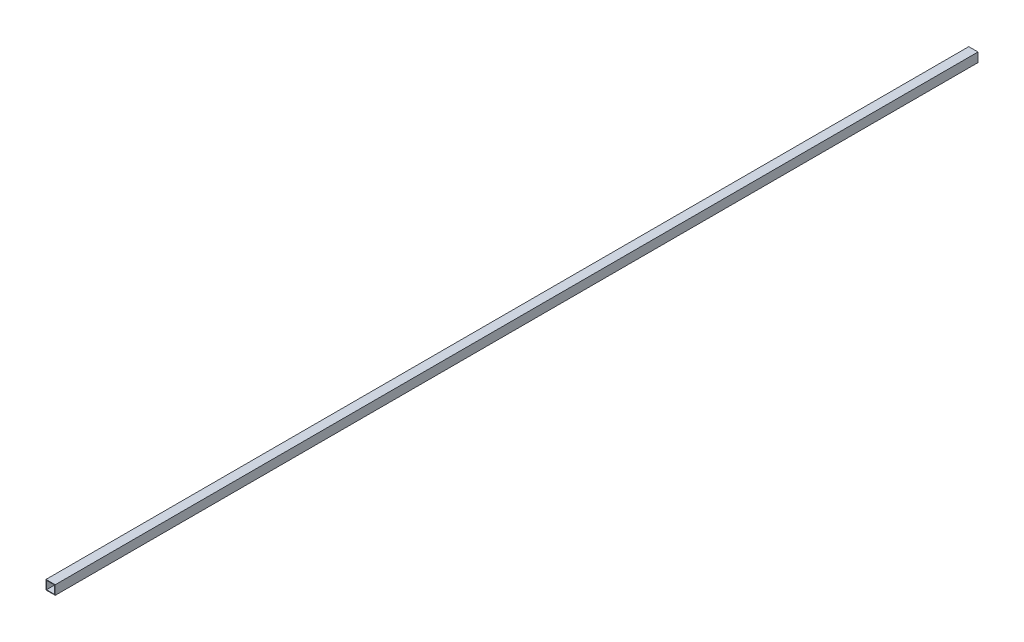
from build123d import *

# Parameters (mm, degrees)
SKETCH1_W           = 25.4
SKETCH1_H           = 25.4
SKETCH1_W_2         = 22.225
SKETCH1_H_2         = 22.225
BOSS_EXTRUDE1_DEPTH = 1270


with BuildPart() as part:
    # Sketch1 → Boss-Extrude1 (new body, symmetric)
    with BuildSketch(Plane.XY):
        Rectangle(SKETCH1_W, SKETCH1_H)
        Rectangle(SKETCH1_W_2, SKETCH1_H_2, mode=Mode.SUBTRACT)
    extrude(amount=BOSS_EXTRUDE1_DEPTH, both=True)


solid = part.part
